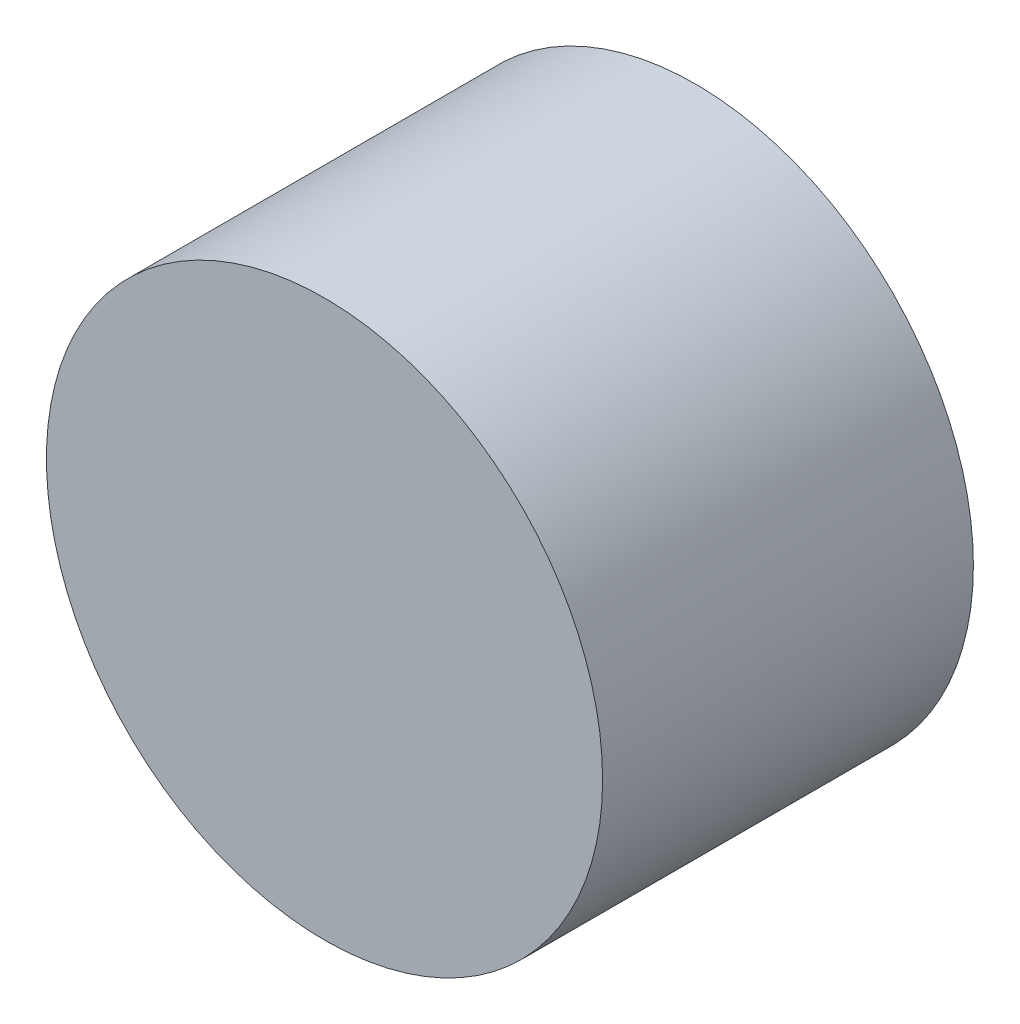
from build123d import *

# Parameters (mm, degrees)
SKETCH1_R           = 7.5
BOSS_EXTRUDE1_DEPTH = 10


with BuildPart() as part:
    # Sketch1 → Boss-Extrude1 (new body)
    with BuildSketch(Plane.XY):
        with Locations((0, 0.748235414)):
            Circle(SKETCH1_R)
    extrude(amount=BOSS_EXTRUDE1_DEPTH)


solid = part.part
